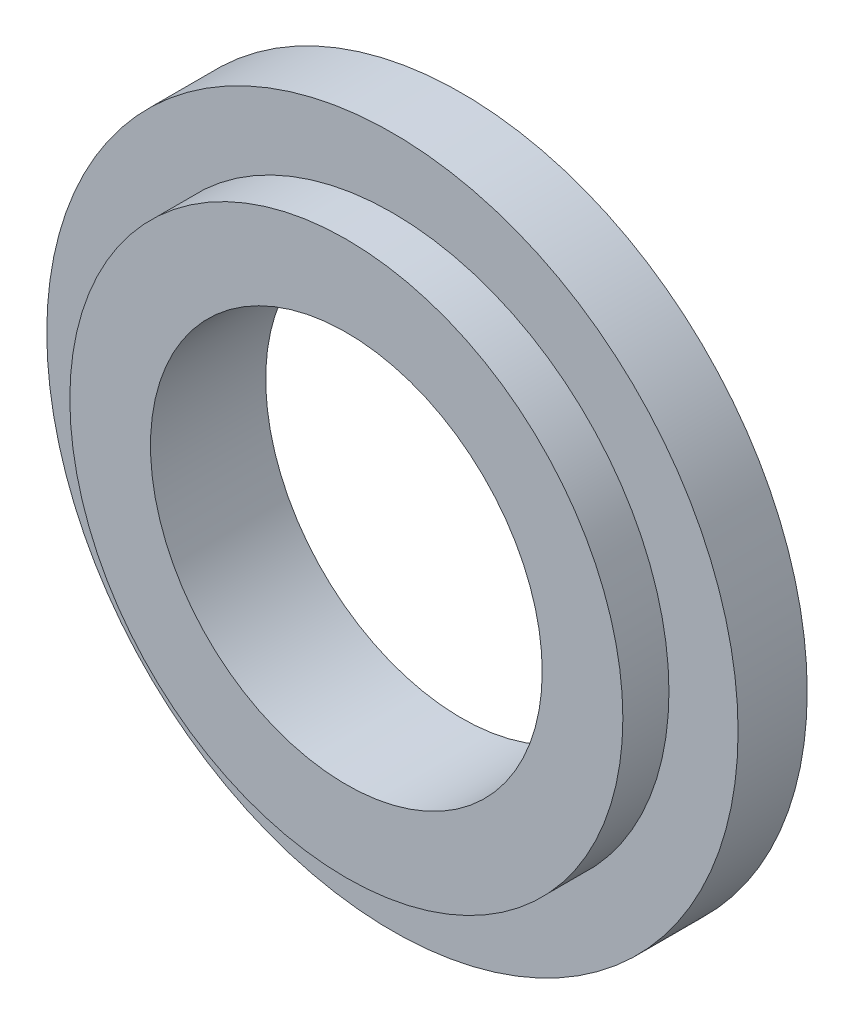
from build123d import *

# Parameters (mm, degrees)
SKETCH1_R           = 15
SKETCH1_R_2         = 8.5
BOSS_EXTRUDE1_DEPTH = 3
SKETCH2_R           = 12
SKETCH2_R_2         = 8.5
BOSS_EXTRUDE2_DEPTH = 2


with BuildPart() as part:
    # Sketch1 → Boss-Extrude1 (new body)
    with BuildSketch(Plane.XY):
        Circle(SKETCH1_R)
        Circle(SKETCH1_R_2, mode=Mode.SUBTRACT)
    extrude(amount=BOSS_EXTRUDE1_DEPTH)

    # Sketch2 → Boss-Extrude2 (add)
    with BuildSketch(Plane.XY.offset(3)):
        Circle(SKETCH2_R)
        Circle(SKETCH2_R_2, mode=Mode.SUBTRACT)
    extrude(amount=BOSS_EXTRUDE2_DEPTH)


solid = part.part
